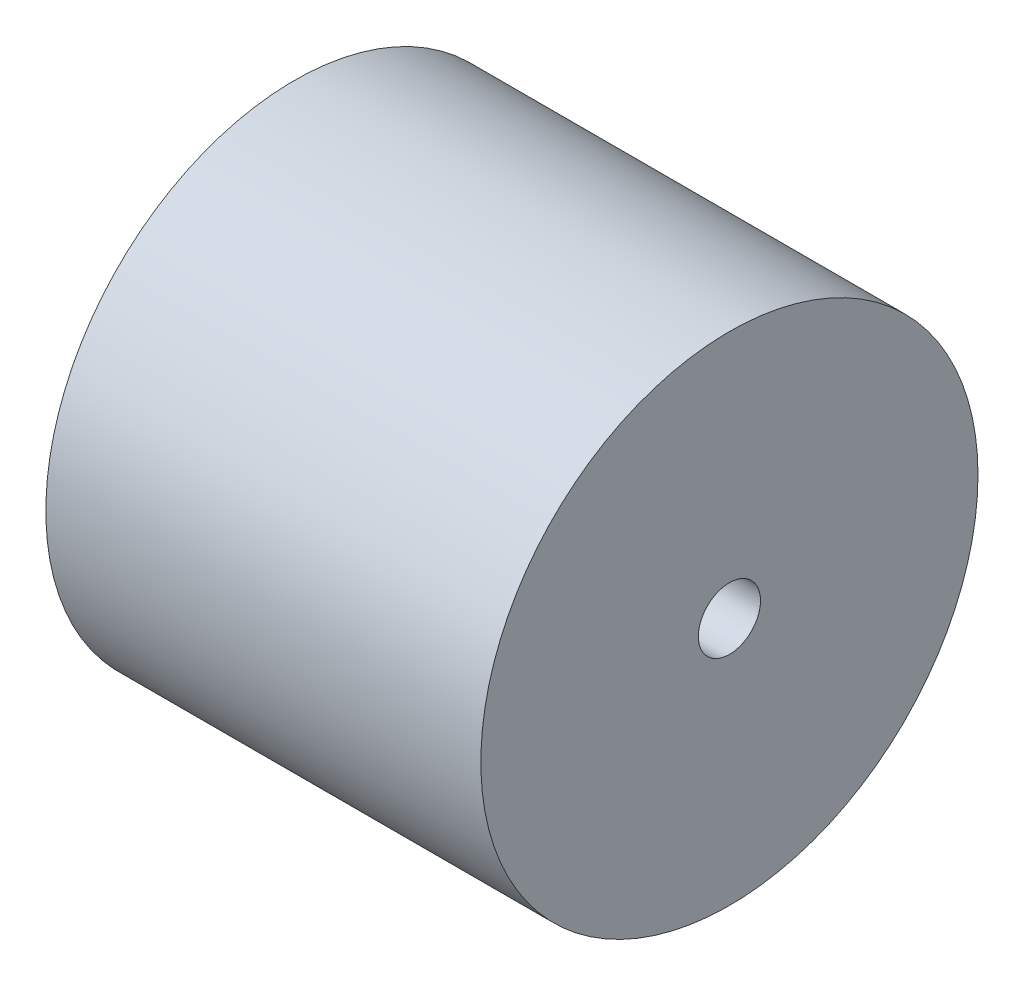
from build123d import *

# Parameters (mm, degrees)
SKETCH1_R           = 50.8
SKETCH1_R_2         = 6.35
BOSS_EXTRUDE1_DEPTH = 44.45


with BuildPart() as part:
    # Sketch1 → Boss-Extrude1 (new body, symmetric)
    with BuildSketch(Plane(origin=(0, 0, 0), x_dir=(0, 0, -1), z_dir=(1, 0, 0))):
        Circle(SKETCH1_R)
        Circle(SKETCH1_R_2, mode=Mode.SUBTRACT)
    extrude(amount=BOSS_EXTRUDE1_DEPTH, both=True)


solid = part.part
